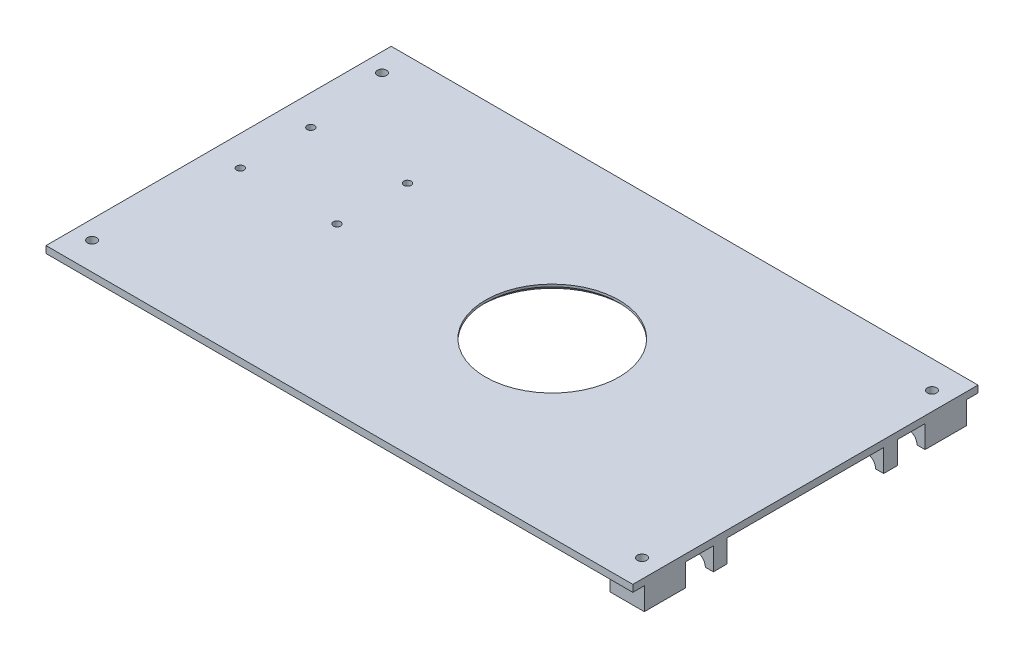
from build123d import *

# Parameters (mm, degrees)
SKETCH1_W               = 255
SKETCH1_H               = 150
BOSS_EXTRUDE1_DEPTH     = 3
SKETCH3_R               = 29
CUT_EXTRUDE2_DEPTH      = 3
CUT_EXTRUDE3_REACH      = 149.954
SKETCH4_R               = 1.6
SKETCH5_W               = 15
SKETCH5_H               = 6
BOSS_EXTRUDE2_DEPTH     = 9.8
CUT_EXTRUDE4_REACH      = 184.352
SKETCH6_R               = 4
SKETCH7_R               = 5
CUT_EXTRUDE5_DEPTH      = 2
SKETCH8_W               = 15
SKETCH8_H               = 18
SKETCH8_H_2             = 6
BOSS_EXTRUDE3_DEPTH     = 9.8
SKETCH9_R               = 4
CUT_EXTRUDE6_DEPTH      = 24
SKETCH10_R              = 5
CUT_EXTRUDE7_DEPTH      = 2
LPATTERN1_COUNT         = 2
LPATTERN1_PITCH         = 18
MIRROR2_COPY_1_SKETCH_R = 5
MIRROR2_COPY_1_DEPTH    = 2
CHAMFER1_SIZE           = 2
F_4_0MM_DOWEL_HOLE1_D   = 4


with BuildPart() as part:
    # Sketch1 → Boss-Extrude1 (new body)
    with BuildSketch(Plane(origin=(0, 0, 0), x_dir=(1, 0, 0), z_dir=(0, 1, 0))):
        Rectangle(SKETCH1_W, SKETCH1_H)
    extrude(amount=BOSS_EXTRUDE1_DEPTH)

    # Sketch3 → Cut-Extrude2 (cut)
    with BuildSketch(Plane(origin=(0, 3, 0), x_dir=(1, 0, 0), z_dir=(0, 1, 0))):
        with Locations(Location((17.5, 0, 0), (0, 0, 270))):
            Circle(SKETCH3_R)
    extrude(amount=-CUT_EXTRUDE2_DEPTH, mode=Mode.SUBTRACT)

    # Sketch4 → Cut-Extrude3 (cut, up to next)
    with BuildSketch(Plane(origin=(0, 3, 0), x_dir=(1, 0, 0), z_dir=(0, 1, 0)), mode=Mode.PRIVATE) as cut_extrude3_sk1:
        with Locations(Location((-72.421312687, -3.64086936, 0), (0, 0, 270))):
            Circle(SKETCH4_R)
    cut_extrude3_tool1 = extrude(cut_extrude3_sk1.sketch, amount=-CUT_EXTRUDE3_REACH, mode=Mode.PRIVATE) & part.part
    # Sketch4 → Cut-Extrude3 (cut, up to next)
    with BuildSketch(Plane(origin=(0, 3, 0), x_dir=(1, 0, 0), z_dir=(0, 1, 0)), mode=Mode.PRIVATE) as cut_extrude3_sk2:
        with Locations(Location((-72.421312687, 26.99913064, 0), (0, 0, 270))):
            Circle(SKETCH4_R)
    cut_extrude3_tool2 = extrude(cut_extrude3_sk2.sketch, amount=-CUT_EXTRUDE3_REACH, mode=Mode.PRIVATE) & part.part
    # Sketch4 → Cut-Extrude3 (cut, up to next)
    with BuildSketch(Plane(origin=(0, 3, 0), x_dir=(1, 0, 0), z_dir=(0, 1, 0)), mode=Mode.PRIVATE) as cut_extrude3_sk3:
        with Locations(Location((-114.421312687, -3.64086936, 0), (0, 0, 270))):
            Circle(SKETCH4_R)
    cut_extrude3_tool3 = extrude(cut_extrude3_sk3.sketch, amount=-CUT_EXTRUDE3_REACH, mode=Mode.PRIVATE) & part.part
    # Sketch4 → Cut-Extrude3 (cut, up to next)
    with BuildSketch(Plane(origin=(0, 3, 0), x_dir=(1, 0, 0), z_dir=(0, 1, 0)), mode=Mode.PRIVATE) as cut_extrude3_sk4:
        with Locations(Location((-114.421312687, 26.99913064, 0), (0, 0, 270))):
            Circle(SKETCH4_R)
    cut_extrude3_tool4 = extrude(cut_extrude3_sk4.sketch, amount=-CUT_EXTRUDE3_REACH, mode=Mode.PRIVATE) & part.part
    add(cut_extrude3_tool1.solids().sort_by_distance((-72.421313, 3, 3.640869))[0], mode=Mode.SUBTRACT)
    add(cut_extrude3_tool2.solids().sort_by_distance((-72.421313, 3, -26.999131))[0], mode=Mode.SUBTRACT)
    add(cut_extrude3_tool3.solids().sort_by_distance((-114.421313, 3, 3.640869))[0], mode=Mode.SUBTRACT)
    add(cut_extrude3_tool4.solids().sort_by_distance((-114.421313, 3, -26.999131))[0], mode=Mode.SUBTRACT)

    # Sketch5 → Boss-Extrude2 (add)
    with BuildSketch(Plane(origin=(0, 0, 0), x_dir=(1, 0, 0), z_dir=(0, 1, 0))):
        with Locations((-114.9, -52)):
            Rectangle(SKETCH5_W, SKETCH5_H)
    boss_extrude2 = extrude(amount=-BOSS_EXTRUDE2_DEPTH)

    # Sketch6 → Cut-Extrude4 (cut, up to next)
    with BuildSketch(Plane.XY.offset(55), mode=Mode.PRIVATE) as cut_extrude4_sk1:
        with Locations((-114.9, -9.8)):
            Circle(SKETCH6_R)
    cut_extrude4_tool1 = extrude(cut_extrude4_sk1.sketch, amount=-CUT_EXTRUDE4_REACH, mode=Mode.PRIVATE) & part.part
    cut_extrude4 = cut_extrude4_tool1.solids().sort_by_distance((-114.9, -9.8, 55))[0]
    add(cut_extrude4, mode=Mode.SUBTRACT)

    # Sketch7 → Cut-Extrude5 (cut, symmetric)
    with BuildSketch(Plane.XY.offset(52)):
        with Locations((-114.9, -9.8)):
            Circle(SKETCH7_R)
    cut_extrude5 = extrude(amount=CUT_EXTRUDE5_DEPTH, both=True, mode=Mode.SUBTRACT)

    # Mirror1: Boss-Extrude2, Cut-Extrude4, Cut-Extrude5 across plane
    add(boss_extrude2.mirror(Plane.XY))
    add(cut_extrude4.mirror(Plane.XY), mode=Mode.SUBTRACT)
    add(cut_extrude5.mirror(Plane.XY), mode=Mode.SUBTRACT)

    # Sketch8 → Boss-Extrude3 (add)
    with BuildSketch(Plane.XZ):
        with Locations((120, -61)):
            Rectangle(SKETCH8_W, SKETCH8_H)
        with Locations((120, -37)):
            Rectangle(SKETCH8_W, SKETCH8_H_2)
    boss_extrude3 = extrude(amount=BOSS_EXTRUDE3_DEPTH)

    # Sketch9 → Cut-Extrude6 (cut)
    with BuildSketch(Plane.XY.offset(-34)):
        with Locations((120, -9.8)):
            Circle(SKETCH9_R)
    cut_extrude6 = extrude(amount=-CUT_EXTRUDE6_DEPTH, mode=Mode.SUBTRACT)

    # Sketch10 → Cut-Extrude7 (cut, symmetric)
    with BuildSketch(Plane.XY.offset(-37)):
        with Locations((120, -9.8)):
            Circle(SKETCH10_R)
    cut_extrude7 = extrude(amount=CUT_EXTRUDE7_DEPTH, both=True, mode=Mode.SUBTRACT)

    # LPattern1: Cut-Extrude7 ×2
    with Locations(*[(0, 0, -i * LPATTERN1_PITCH) for i in range(1, LPATTERN1_COUNT)]):
        add(cut_extrude7, mode=Mode.SUBTRACT)

    # Mirror2: Boss-Extrude3, Cut-Extrude6, Cut-Extrude7 across plane
    add(boss_extrude3.mirror(Plane.XY))
    add(cut_extrude6.mirror(Plane.XY), mode=Mode.SUBTRACT)
    add(cut_extrude7.mirror(Plane.XY), mode=Mode.SUBTRACT)

    # Mirror2 copy 1 sketch → Mirror2 copy 1 (cut, symmetric)
    with BuildSketch(Plane(origin=(0, 0, 55), x_dir=(1, 0, 0), z_dir=(0, 0, -1))):
        with Locations((120, 9.8)):
            Circle(MIRROR2_COPY_1_SKETCH_R)
    extrude(amount=MIRROR2_COPY_1_DEPTH, both=True, mode=Mode.SUBTRACT)

    # Chamfer1
    chamfer1_edges = [part.edges().sort_by_distance(p)[0] for p in [
        (17.5, 0, -29),
    ]]
    chamfer(chamfer1_edges, length=CHAMFER1_SIZE)

    # Ø4.0mm Dowel Hole1 (through all)
    with Locations(Plane(origin=(0, 3, 0), x_dir=(1, 0, 0), z_dir=(0, 1, 0))):
        with Locations((119.5, -63), (119.5, 63)):
            f_4_0mm_dowel_hole1 = Hole(F_4_0MM_DOWEL_HOLE1_D / 2)

    # Mirror3: Ø4.0mm Dowel Hole1 across plane
    add(f_4_0mm_dowel_hole1.mirror(Plane(origin=(0, 0, 0), x_dir=(0, 0, 1), z_dir=(1, 0, 0))), mode=Mode.SUBTRACT)


solid = part.part
